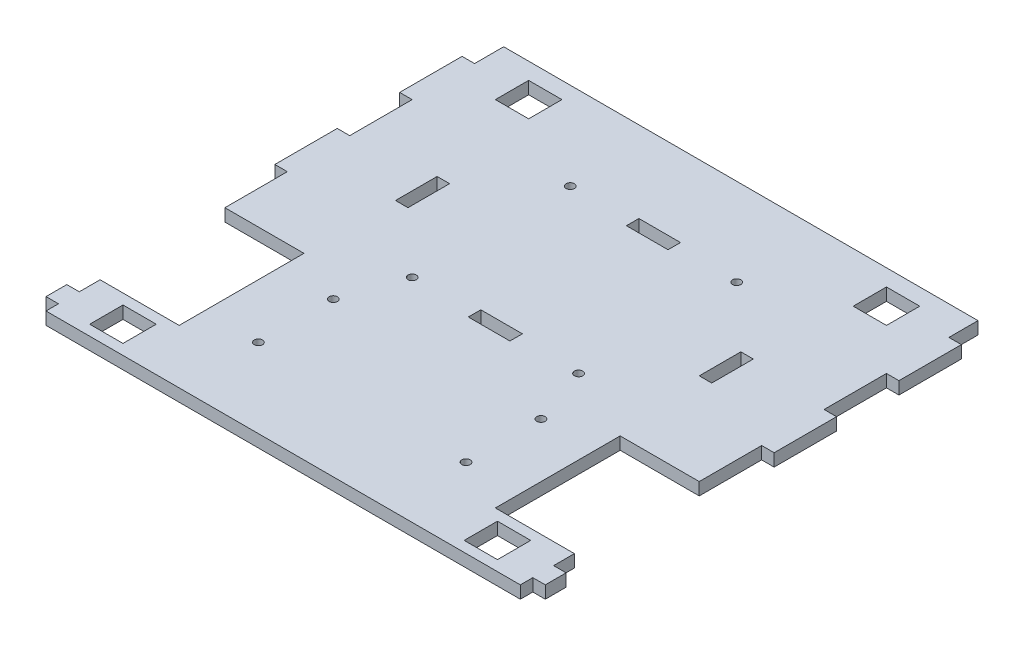
from build123d import *

# Parameters (mm, degrees)
CROQUIS1_W              = 8
CROQUIS1_H              = 8
CROQUIS1_R              = 1
CROQUIS1_W_2            = 10
CROQUIS1_H_2            = 3
CROQUIS1_W_3            = 3
CROQUIS1_H_3            = 10
SALIENTE_EXTRUIR1_DEPTH = 3
CROQUIS2_W              = 114
CROQUIS2_H              = 8
CORTAR_EXTRUIR1_DEPTH   = 4
CROQUIS3_W              = 114
CROQUIS3_H              = 2
CORTAR_EXTRUIR2_DEPTH   = 4


with BuildPart() as part:
    # Croquis1 → Saliente-Extruir1 (new body)
    with BuildSketch(Plane(origin=(0, 0, 0), x_dir=(1, 0, 0), z_dir=(0, 1, 0))):
        Polygon((-57, 0), (-57, -15), (-38, -15), (-38, -45), (-57, -45), (-57, -50), (-60, -50), (-60, -55), (-57, -55), (-57, -60), (57, -60), (57, -55), (60, -55), (60, -50), (57, -50), (57, -45), (38, -45), (38, -15), (57, -15), (57, 0), (60, 0), (60, 15), (57, 15), (57, 30), (60, 30), (60, 45), (57, 45), (57, 60), (-57, 60), (-57, 45), (-60, 45), (-60, 30), (-57, 30), (-57, 15), (-60, 15), (-60, 0), align=None)
        with Locations((-45, -51.5)):
            Rectangle(CROQUIS1_W, CROQUIS1_H, mode=Mode.SUBTRACT)
        with Locations((-24.95, -39)):
            Circle(CROQUIS1_R, mode=Mode.SUBTRACT)
        with Locations((-24.95, -21)):
            Circle(CROQUIS1_R, mode=Mode.SUBTRACT)
        with Locations((-20, -7)):
            Circle(CROQUIS1_R, mode=Mode.SUBTRACT)
        with Locations((24.95, -39)):
            Circle(CROQUIS1_R, mode=Mode.SUBTRACT)
        with Locations((45, -51.5)):
            Rectangle(CROQUIS1_W, CROQUIS1_H, mode=Mode.SUBTRACT)
        with Locations((24.95, -21)):
            Circle(CROQUIS1_R, mode=Mode.SUBTRACT)
        with Locations((0, -7)):
            Rectangle(CROQUIS1_W_2, CROQUIS1_H_2, mode=Mode.SUBTRACT)
        with Locations((20, -7)):
            Circle(CROQUIS1_R, mode=Mode.SUBTRACT)
        with Locations((-36.5, 12)):
            Rectangle(CROQUIS1_W_3, CROQUIS1_H_3, mode=Mode.SUBTRACT)
        with Locations((-43, 44)):
            Rectangle(CROQUIS1_W, CROQUIS1_H, mode=Mode.SUBTRACT)
        with Locations((-20, 31)):
            Circle(CROQUIS1_R, mode=Mode.SUBTRACT)
        with Locations((36.5, 12)):
            Rectangle(CROQUIS1_W_3, CROQUIS1_H_3, mode=Mode.SUBTRACT)
        with Locations((0, 31)):
            Rectangle(CROQUIS1_W_2, CROQUIS1_H_2, mode=Mode.SUBTRACT)
        with Locations((20, 31)):
            Circle(CROQUIS1_R, mode=Mode.SUBTRACT)
        with Locations((43, 44)):
            Rectangle(CROQUIS1_W, CROQUIS1_H, mode=Mode.SUBTRACT)
    extrude(amount=SALIENTE_EXTRUIR1_DEPTH)

    # Croquis2 → Cortar-Extruir1 (cut, through all)
    with BuildSketch(Plane(origin=(0, 3, 0), x_dir=(1, 0, 0), z_dir=(0, 1, 0))):
        with Locations((0, 56)):
            Rectangle(CROQUIS2_W, CROQUIS2_H)
    extrude(amount=-CORTAR_EXTRUIR1_DEPTH, mode=Mode.SUBTRACT)

    # Croquis3 → Cortar-Extruir2 (cut, through all)
    with BuildSketch(Plane(origin=(0, 3, 0), x_dir=(1, 0, 0), z_dir=(0, 1, 0))):
        with Locations((0, -59)):
            Rectangle(CROQUIS3_W, CROQUIS3_H)
    extrude(amount=-CORTAR_EXTRUIR2_DEPTH, mode=Mode.SUBTRACT)


solid = part.part
